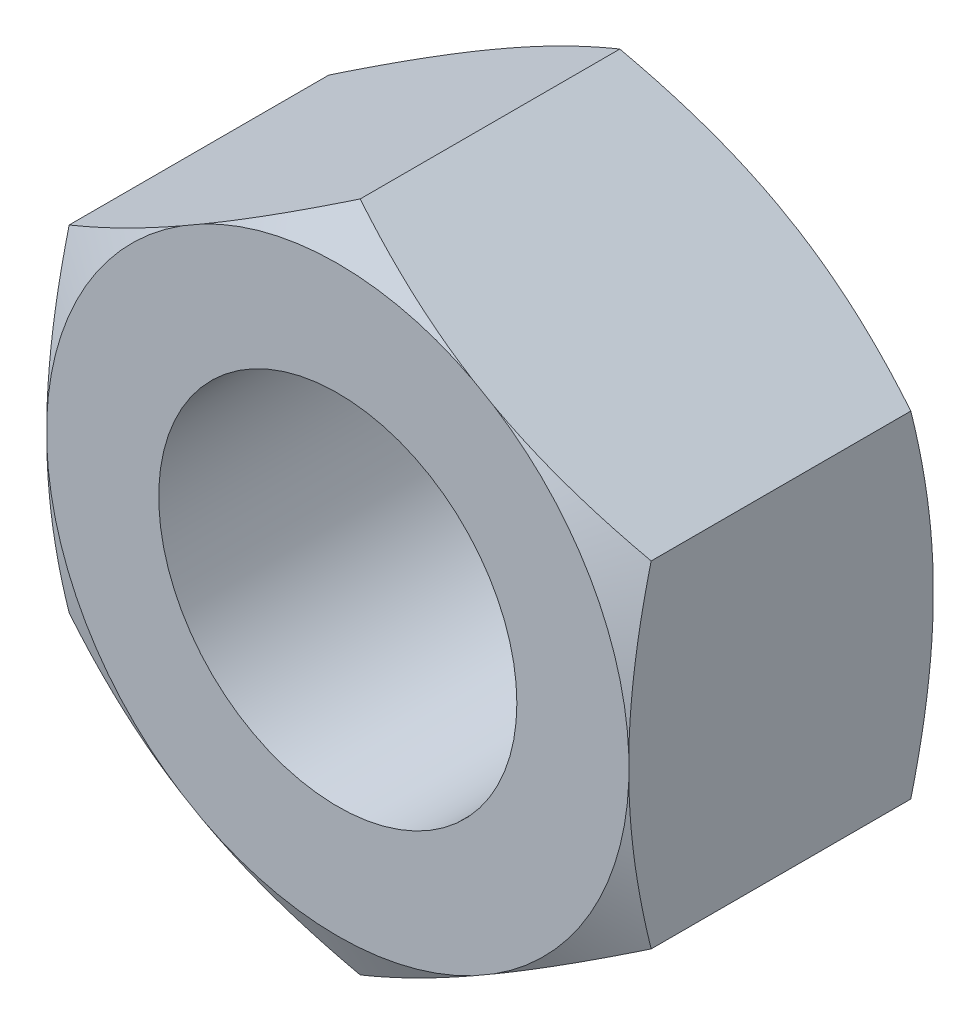
from build123d import *

# Parameters (mm, degrees)
SKETCH1_R           = 4
BOSS_EXTRUDE1_DEPTH = 6.8


with BuildPart() as part:
    # Sketch1 → Boss-Extrude1 (new body)
    with BuildSketch(Plane.XY):
        Polygon((0, -7.505553499), (6.5, -3.75277675), (6.5, 3.75277675), (0, 7.505553499), (-6.5, 3.75277675), (-6.5, -3.75277675), align=None)
        Circle(SKETCH1_R, mode=Mode.SUBTRACT)
    extrude(amount=BOSS_EXTRUDE1_DEPTH)

    # Sketch2 → Cut-Revolve1 (revolve, cut)
    with BuildSketch(Plane(origin=(0, 0, 0), x_dir=(0, 0, -1), z_dir=(1, 0, 0))):
        Polygon((-6.8, 7.505553499), (-6.3, 7.505553499), (-6.8, 6.505553499), align=None)
        Polygon((0, 6.505553499), (-0.5, 7.505553499), (0, 7.505553499), align=None)
    revolve(axis=Axis((0, 0, 8.433189241), (0, 0, -1)), mode=Mode.SUBTRACT)


solid = part.part
